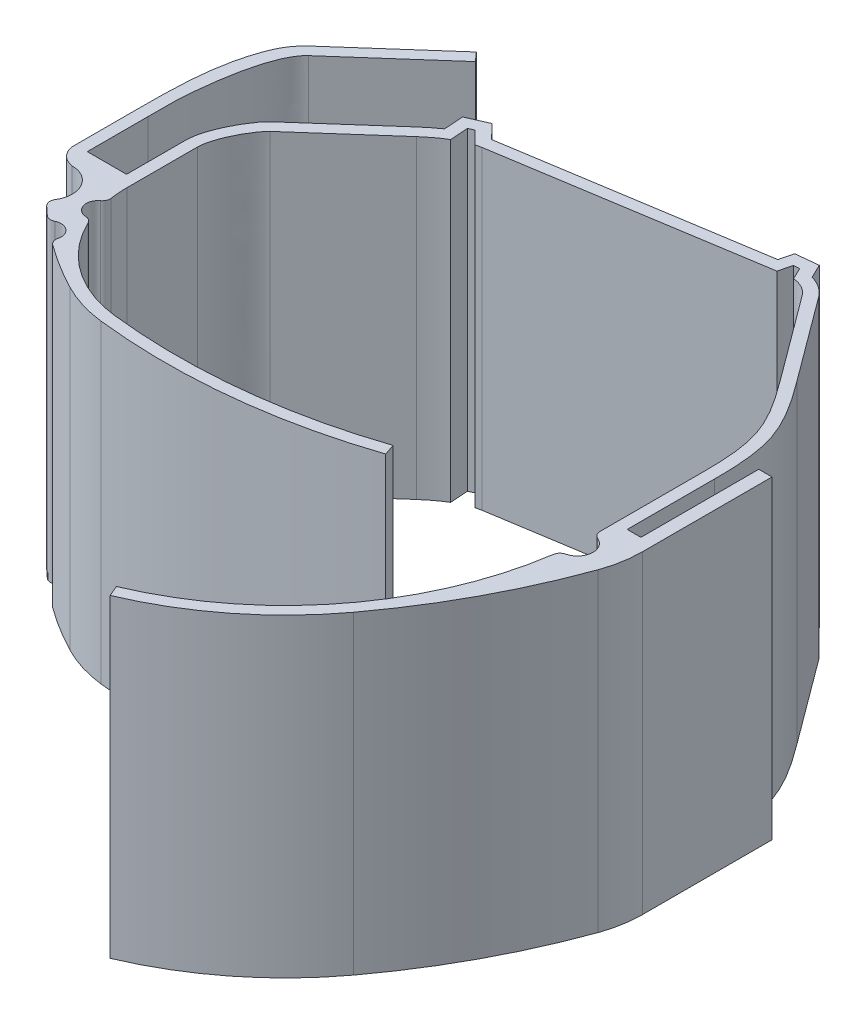
from build123d import *

# Parameters (mm, degrees)
BOSS_EXTRUDE1_DEPTH = 40
BOSS_EXTRUDE2_DEPTH = 40
CUT_EXTRUDE2_DEPTH  = 89.127785941
SKETCH6_W           = 1.5
SKETCH6_H           = 7.722178365
BOSS_EXTRUDE3_DEPTH = 40
BOSS_EXTRUDE4_DEPTH = 40
CUT_EXTRUDE3_DEPTH  = 100.042088428
SKETCH9_R           = 1.978973178
CUT_EXTRUDE4_DEPTH  = 100.042088428
FILLET1_R           = 1


with BuildPart() as part:
    # Sketch1 → Boss-Extrude1 (new body)
    with BuildSketch(Plane(origin=(0, 0, 0), x_dir=(1, 0, 0), z_dir=(0, 1, 0))):
        with BuildLine():
            Line((20.398121418, 24.345578176), (53.978810709, 29.668857871))
            ThreePointArc((53.978810709, 29.668857871), (56.544470242, 29.371380566), (58.583761071, 27.786327097))
            Line((58.583761071, 27.786327097), (66.486417585, 17.115166521))
            add(Edge.make_bspline(
                [(66.486417585, 17.115166521), (68.176728944, 14.83269557), (71.776817797, 9.799279034), (72, 3.897307111), (72, 1.114799258)],
                knots=[0, 0, 0, 0, 0.517914669, 1, 1, 1, 1], degree=3))
            Line((72, 1.114799258), (72, -10))
            Line((72, -10), (70.5, -10))
            Line((70.5, -10), (70.5, 1.114799258))
            add(Edge.make_bspline(
                [(65.280978775, 16.222464289), (65.692293377, 15.667055592), (66.504818489, 14.559302163), (67.686202227, 12.807430897), (68.722550831, 11.005909815), (69.535381009, 9.176979834), (70.055214347, 7.307010456), (70.355420591, 5.311555037), (70.485554087, 3.244250323), (70.5, 1.820940625), (70.5, 1.114799258)],
                knots=[0, 0, 0, 0, 0.125, 0.25, 0.375, 0.5, 0.625, 0.75, 0.875, 1, 1, 1, 1], degree=3))
            Line((65.280978775, 16.222464289), (57.378322261, 26.893624865))
            ThreePointArc((57.378322261, 26.893624865), (55.976860008, 27.982921484), (54.213661284, 28.187356873))
            Line((54.213661284, 28.187356873), (20.632971992, 22.864077178))
            add(Edge.make_bspline(
                [(15.281910435, 19.878213101), (15.682547509, 20.232184409), (16.502218359, 20.906225538), (17.867713458, 21.830474009), (19.264020762, 22.530230982), (20.16214342, 22.789440468), (20.632971992, 22.864077178)],
                knots=[0, 0, 0, 0, 0.25, 0.5, 0.75, 1, 1, 1, 1], degree=3))
            Line((15.281910435, 19.878213101), (5.406877663, 11.153413307))
            add(Edge.make_bspline(
                [(2.5, 4.782232795), (2.5, 4.903872239), (2.511841261, 5.134723782), (2.586627694, 5.692200835), (2.775708514, 6.465904526), (3.13226574, 7.462133736), (3.583192684, 8.454904833), (4.088651961, 9.386456831), (4.60797986, 10.201327145), (5.003578788, 10.726147872), (5.276521582, 11.030615761), (5.356389157, 11.108805647), (5.406877663, 11.153413307)],
                knots=[0, 0, 0, 0, 0.0625, 0.125, 0.25, 0.375, 0.5, 0.625, 0.75, 0.875, 0.9375, 1, 1, 1, 1], degree=3))
            Line((2.5, 4.782232795), (2.5, 0))
            Line((2.5, 0), (2.5, -2.717767205))
            Line((2.5, -2.717767205), (1, -2.717767205))
            Line((1, -2.717767205), (1, 0))
            Line((1, 0), (1, 4.782232795))
            add(Edge.make_bspline(
                [(1, 4.782232795), (1, 7.414060911), (3.19289931, 11.198908949), (4.413707105, 12.277518392)],
                knots=[0, 0, 0, 0, 1, 1, 1, 1], degree=3))
            Line((4.413707105, 12.277518392), (14.288739877, 21.002318186))
            add(Edge.make_bspline(
                [(14.288739877, 21.002318186), (15.276617467, 21.875128879), (17.244426658, 23.360900284), (19.445371202, 24.194546259), (20.398121418, 24.345578176)],
                knots=[0, 0, 0, 0, 0.592258741, 1, 1, 1, 1], degree=3))
        make_face()
    extrude(amount=BOSS_EXTRUDE1_DEPTH)

    # Sketch3 → Boss-Extrude2 (add)
    with BuildSketch(Plane(origin=(0, 40, 0), x_dir=(1, 0, 0), z_dir=(0, 1, 0))):
        with BuildLine():
            add(Edge.make_bspline(
                [(18.751053449, 23.891674154), (19.282779891, 24.098650126), (19.830635044, 24.255619073), (20.398121418, 24.345578176)],
                knots=[0.757137176, 0.757137176, 0.757137176, 0.757137176, 1, 1, 1, 1], degree=3))
            Line((20.398121418, 24.345578176), (18.661234099, 26.143694535))
            Line((18.661234099, 26.143694535), (16.057216425, 24.983892291))
            Line((16.057216425, 24.983892291), (16.229535628, 22.524357593))
            add(Edge.make_bspline(
                [(16.229535628, 22.524357593), (16.693343005, 22.841460134), (17.176192758, 23.137385715), (17.672053929, 23.397283412)],
                knots=[0.353921019, 0.353921019, 0.353921019, 0.353921019, 0.589528277, 0.589528277, 0.589528277, 0.589528277], degree=3))
            Line((17.672053929, 23.397283412), (17.626955102, 24.040984912))
            Line((17.626955102, 24.040984912), (18.312073239, 24.346129366))
            Line((18.312073239, 24.346129366), (18.751053449, 23.891674154))
        make_face()
        with BuildLine():
            Line((52.27527464, 31.049242495), (51.845332293, 29.3306545))
            Line((51.845332293, 29.3306545), (53.455411574, 29.585887568))
            Line((53.455411574, 29.585887568), (53.475526819, 29.666293273))
            Line((53.475526819, 29.666293273), (54.221480276, 29.744097128))
            Line((54.221480276, 29.744097128), (54.241442345, 29.703086175))
            ThreePointArc((54.241442345, 29.703086175), (55.116171363, 29.712405203), (55.97804164, 29.562681044))
            Line((55.97804164, 29.562681044), (55.110517033, 31.344961734))
            Line((55.110517033, 31.344961734), (52.27527464, 31.049242495))
        make_face()
    extrude(amount=-BOSS_EXTRUDE2_DEPTH)

    # Sketch3_4 → Cut-Extrude2 (cut, through all)
    with BuildSketch(Plane(origin=(0, 40, 0), x_dir=(1, 0, 0), z_dir=(0, 1, 0))):
        with BuildLine():
            add(Edge.make_bspline(
                [(17.787977134, 21.74269623), (17.816245551, 21.759621723), (18.304522018, 22.049379858), (19.01849468, 22.407186014), (19.686088595, 22.638281293), (19.901634045, 22.7005331)],
                knots=[0.484623438, 0.484623438, 0.484623438, 0.484623438, 0.5, 0.75, 0.868120319, 0.868120319, 0.868120319, 0.868120319], degree=3))
            Line((19.901634045, 22.7005331), (18.312073239, 24.346129366))
            Line((18.312073239, 24.346129366), (17.626955102, 24.040984912))
            Line((17.626955102, 24.040984912), (17.787977134, 21.74269623))
        make_face()
        with BuildLine():
            Line((53.475526819, 29.666293273), (53.05977814, 28.004440952))
            Line((53.05977814, 28.004440952), (54.213661284, 28.187356873))
            ThreePointArc((54.213661284, 28.187356873), (54.587646839, 28.224941588), (54.963479702, 28.219700888))
            Line((54.963479702, 28.219700888), (54.221480276, 29.744097128))
            Line((54.221480276, 29.744097128), (53.475526819, 29.666293273))
        make_face()
    extrude(amount=-CUT_EXTRUDE2_DEPTH, mode=Mode.SUBTRACT)

    # Sketch6 → Boss-Extrude3 (add)
    with BuildSketch(Plane(origin=(0, 40, 0), x_dir=(1, 0, 0), z_dir=(0, 1, 0))):
        with BuildLine():
            add(Edge.make_bspline(
                [(-4, 5.00441116), (-4, 7.148885888), (-4.150620184, 9.842190951), (-2.62823203, 20.066962186), (-0.504563273, 21.943268337)],
                knots=[0, 0, 0, 0, 0.427266447, 1, 1, 1, 1], degree=3))
            Line((-0.504563273, 21.943268337), (10.772019145, 31.906366813))
            Line((10.772019145, 31.906366813), (9.778848586, 33.030471898))
            Line((9.778848586, 33.030471898), (-1.497733832, 23.067373422))
            add(Edge.make_bspline(
                [(-1.497733832, 23.067373422), (-2.864560982, 21.859752798), (-5.384291278, 16.169019706), (-5.5, 10.323001546), (-5.5, 5.00441116)],
                knots=[0, 0, 0, 0, 0.256758401, 1, 1, 1, 1], degree=3))
            Line((-5.5, 5.00441116), (-4, 5.00441116))
        make_face()
        with Locations((-4.75, 1.143321977)):
            Rectangle(SKETCH6_W, SKETCH6_H)
        Polygon((1, -2.717767205), (-4, -2.717767205), (-5.5, -2.717767205), (-5.5, -4.170592773), (2.5, -4.170592773), (2.5, -2.717767205), align=None)
        Polygon((72, -10), (70.5, -10), (70.5, -11.5), (73.75, -11.5), (73.75, -10), align=None)
        Polygon((73.75, 5), (73.75, -10), (73.75, -11.5), (75.437972218, -11.5), (75.437972218, 5), align=None)
    extrude(amount=-BOSS_EXTRUDE3_DEPTH)

    # Sketch7 → Boss-Extrude4 (add)
    with BuildSketch(Plane(origin=(0, 40, 0), x_dir=(1, 0, 0), z_dir=(0, 1, 0))):
        with BuildLine():
            ThreePointArc((-4.476094057, -7.064927363), (2.098628192, -13.668931959), (9.886508821, -18.786427896))
            ThreePointArc((9.886508821, -18.786427896), (12.652360348, -19.914867799), (15.576592256, -20.524932575))
            ThreePointArc((15.576592256, -20.524932575), (32.14204183, -20.601906953), (48.323769108, -17.056241015))
            Line((48.323769108, -17.056241015), (47.843551052, -15.635188371))
            ThreePointArc((47.843551052, -15.635188371), (31.98404066, -19.110251621), (15.7484488, -19.034809987))
            ThreePointArc((15.7484488, -19.034809987), (6.292822959, -14.12632415), (2.5, -4.170592773))
            Line((2.5, -4.170592773), (-5.5, -4.170592773))
            ThreePointArc((-5.5, -4.170592773), (-5.23647988, -5.7056462), (-4.476094057, -7.064927363))
        make_face()
        with BuildLine():
            ThreePointArc((70.5, -11.5), (63.762751126, -33.871905177), (45.791791135, -48.802988885))
            Line((45.791791135, -48.802988885), (46.3769665, -50.184136883))
            ThreePointArc((46.3769665, -50.184136883), (55.960128705, -44.522561304), (63.720257778, -36.543160785))
            ThreePointArc((63.720257778, -36.543160785), (69.898474001, -26.813356293), (74.598218012, -16.289485456))
            ThreePointArc((74.598218012, -16.289485456), (75.226444538, -13.931273229), (75.437972218, -11.5))
            Line((75.437972218, -11.5), (70.5, -11.5))
        make_face()
    extrude(amount=-BOSS_EXTRUDE4_DEPTH)

    # Sketch8 → Cut-Extrude3 (cut, through all)
    with BuildSketch(Plane(origin=(0, 40, 0), x_dir=(1, 0, 0), z_dir=(0, 1, 0))):
        with BuildLine():
            Line((-5.5, -3.134058573), (-5.5, -4.170592773))
            ThreePointArc((-5.5, -4.170592773), (-5.23647988, -5.7056462), (-4.476094057, -7.064927363))
            ThreePointArc((-4.476094057, -7.064927363), (-2.912867968, -8.896017688), (-1.254482008, -10.641389736))
            ThreePointArc((-1.254482008, -10.641389736), (-0.485075756, -7.222773034), (-3.382312305, -5.251746267))
            ThreePointArc((-3.382312305, -5.251746267), (-4.802479659, -4.554225926), (-5.5, -3.134058573))
        make_face()
        with BuildLine():
            ThreePointArc((1.116647564, -12.844072979), (2.259182497, -13.79935222), (3.432528418, -14.716523879))
            ThreePointArc((3.432528418, -14.716523879), (3.195534686, -12.641255039), (1.116647564, -12.844072979))
        make_face()
        with BuildLine():
            ThreePointArc((3.633583558, -9.883563458), (3.134163572, -8.48052241), (2.776692245, -7.034784276))
            ThreePointArc((2.776692245, -7.034784276), (1.708006827, -8.909499614), (3.633583558, -9.883563458))
        make_face()
    extrude(amount=-CUT_EXTRUDE3_DEPTH, mode=Mode.SUBTRACT)

    # Sketch9 → Cut-Extrude4 (cut, through all)
    with BuildSketch(Plane(origin=(0, 40, 0), x_dir=(1, 0, 0), z_dir=(0, 1, 0))):
        with Locations((70.373266589, -14.701975374)):
            Circle(SKETCH9_R)
    extrude(amount=-CUT_EXTRUDE4_DEPTH, mode=Mode.SUBTRACT)

    # Fillet1
    fillet1_edges = [part.edges().sort_by_distance(p)[0] for p in [
        (-1.254482008, 20, 10.641389736),
        (2.776692245, 20, 7.034784276),
        (3.633583558, 20, 9.883563458),
        (1.116647564, 20, 12.844072979),
        (3.432528418, 20, 14.716523879),
        (70.168720645, 20, 16.67034927),
        (70.481446397, 20, 12.725961212),
    ]]
    fillet(fillet1_edges, radius=FILLET1_R)


solid = part.part
